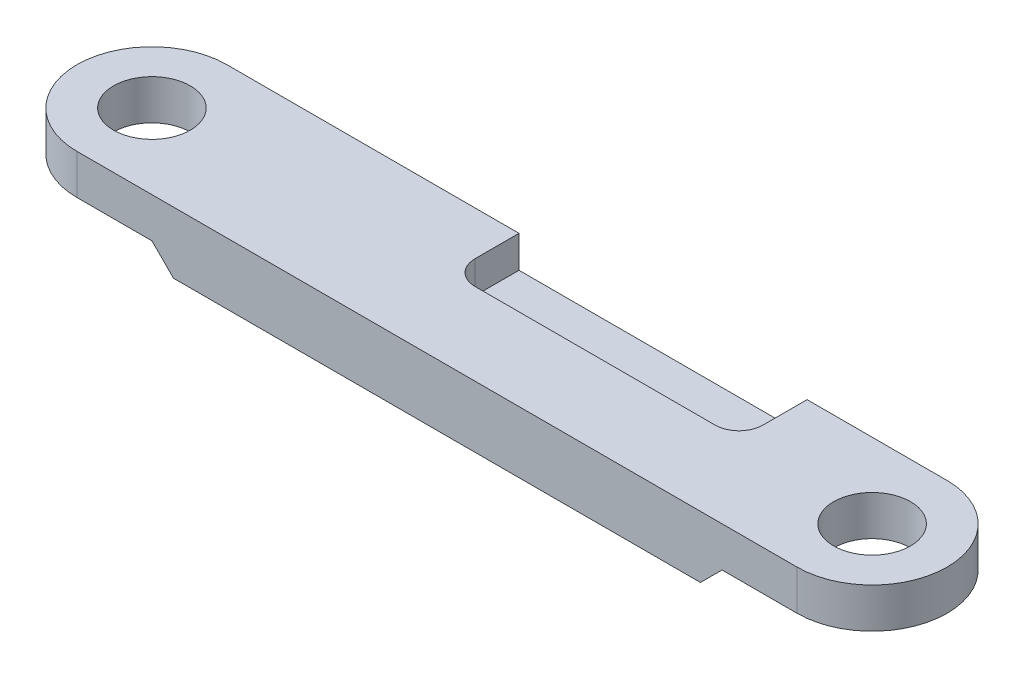
from build123d import *

# Parameters (mm, degrees)
SKETCH1_R           = 1.2192
BOSS_EXTRUDE1_DEPTH = 1.9558
SKETCH3_W           = 9.144
SKETCH3_H           = 1.016
CUT_EXTRUDE1_DEPTH  = 2.159
FILLET1_R           = 0.762
CUT_EXTRUDE2_DEPTH  = 5.7625


with BuildPart() as part:
    # Sketch1 → Boss-Extrude1 (new body)
    with BuildSketch(Plane(origin=(0, 0, 0), x_dir=(1, 0, 0), z_dir=(0, 1, 0))):
        with BuildLine():
            Line((-11.43, 2.38125), (11.43, 2.38125))
            ThreePointArc((11.43, 2.38125), (13.81125, 0), (11.43, -2.38125))
            Line((11.43, -2.38125), (-11.43, -2.38125))
            ThreePointArc((-11.43, -2.38125), (-13.81125, 0), (-11.43, 2.38125))
        make_face()
        with Locations((-11.43, 0)):
            Circle(SKETCH1_R, mode=Mode.SUBTRACT)
        with Locations((11.43, 0)):
            Circle(SKETCH1_R, mode=Mode.SUBTRACT)
    extrude(amount=BOSS_EXTRUDE1_DEPTH)

    # Sketch3 → Cut-Extrude1 (cut)
    with BuildSketch(Plane(origin=(0, 0, -2.38125), x_dir=(-1, 0, 0), z_dir=(0, 0, -1))):
        with Locations((-2.413, 1.4478)):
            Rectangle(SKETCH3_W, SKETCH3_H)
    extrude(amount=-CUT_EXTRUDE1_DEPTH, mode=Mode.SUBTRACT)

    # Fillet1
    fillet1_edges = [part.edges().sort_by_distance(p)[0] for p in [
        (6.985, 1.4478, -0.22225),
        (-2.159, 1.4478, -0.22225),
    ]]
    fillet(fillet1_edges, radius=FILLET1_R)

    # Sketch4 → Cut-Extrude2 (cut, through all)
    with BuildSketch(Plane(origin=(0, 0, -2.38125), x_dir=(-1, 0, 0), z_dir=(0, 0, -1))):
        Polygon((-8.36295, 0), (-9.04875, 0.6858), (-14.591138831, 0.6858), (-14.591138831, 0), align=None)
        Polygon((14.591138831, 0.6858), (14.591138831, 0), (8.36295, 0), (9.04875, 0.6858), align=None)
    extrude(amount=-CUT_EXTRUDE2_DEPTH, mode=Mode.SUBTRACT)


solid = part.part
